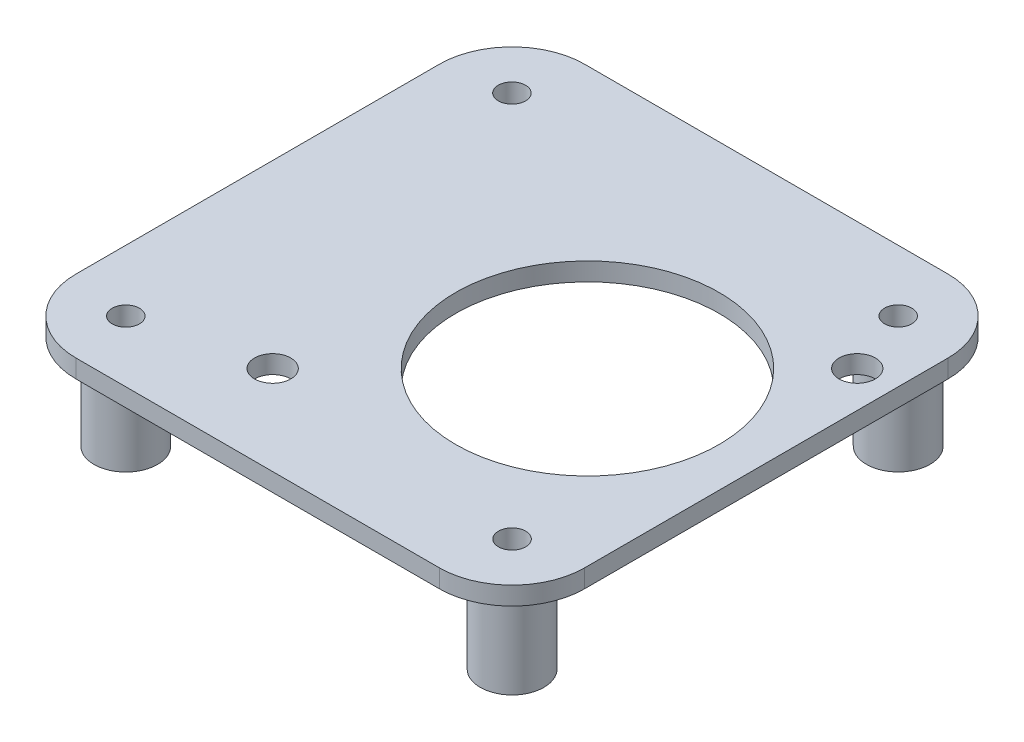
from build123d import *

# Parameters (mm, degrees)
SKETCH1_W           = 71.12
SKETCH1_H           = 71.12
SKETCH1_R           = 1.905
BOSS_EXTRUDE1_DEPTH = 2.54
SKETCH2_R           = 2.54
SKETCH2_R_2         = 18.415
CUT_EXTRUDE1_DEPTH  = 3.54
SKETCH3_R           = 4.445
SKETCH3_R_2         = 1.905
BOSS_EXTRUDE2_DEPTH = 13.208
FILLET1_R           = 10.16


with BuildPart() as part:
    # Sketch1 → Boss-Extrude1 (new body)
    with BuildSketch(Plane(origin=(0, 0, 0), x_dir=(1, 0, 0), z_dir=(0, 1, 0))):
        with Locations((35.56, 35.56)):
            Rectangle(SKETCH1_W, SKETCH1_H)
        with Locations((8.5598, 62.5475)):
            Circle(SKETCH1_R, mode=Mode.SUBTRACT)
        with Locations((62.5475, 62.5602)):
            Circle(SKETCH1_R, mode=Mode.SUBTRACT)
        with Locations((62.5602, 8.5725)):
            Circle(SKETCH1_R, mode=Mode.SUBTRACT)
        with Locations((8.5725, 8.5598)):
            Circle(SKETCH1_R, mode=Mode.SUBTRACT)
    extrude(amount=BOSS_EXTRUDE1_DEPTH)

    # Sketch2 → Cut-Extrude1 (cut, through all)
    with BuildSketch(Plane(origin=(0, 2.54, 0), x_dir=(1, 0, 0), z_dir=(0, 1, 0))):
        with Locations((25.179834649, 12.479834649)):
            Circle(SKETCH2_R)
        with Locations((66.04, 53.34)):
            Circle(SKETCH2_R)
        with Locations((47.181462146, 34.481462146)):
            Circle(SKETCH2_R_2)
    extrude(amount=-CUT_EXTRUDE1_DEPTH, mode=Mode.SUBTRACT)

    # Sketch3 → Boss-Extrude2 (add)
    with BuildSketch(Plane.XZ):
        with Locations((62.5602, -8.5725)):
            Circle(SKETCH3_R)
        with Locations((62.5602, -8.5725)):
            Circle(SKETCH3_R_2, mode=Mode.SUBTRACT)
        with Locations((62.5475, -62.5602)):
            Circle(SKETCH3_R)
        with Locations((62.5475, -62.5602)):
            Circle(SKETCH3_R_2, mode=Mode.SUBTRACT)
        with Locations((8.5598, -62.5475)):
            Circle(SKETCH3_R)
        with Locations((8.5598, -62.5475)):
            Circle(SKETCH3_R_2, mode=Mode.SUBTRACT)
        with Locations((8.5725, -8.5598)):
            Circle(SKETCH3_R)
        with Locations((8.5725, -8.5598)):
            Circle(SKETCH3_R_2, mode=Mode.SUBTRACT)
    extrude(amount=BOSS_EXTRUDE2_DEPTH)

    # Fillet1
    fillet1_edges = [part.edges().sort_by_distance(p)[0] for p in [
        (0, 1.27, -71.12),
        (71.12, 1.27, -71.12),
        (71.12, 1.27, 0),
        (0, 1.27, 0),
    ]]
    fillet(fillet1_edges, radius=FILLET1_R)


solid = part.part
